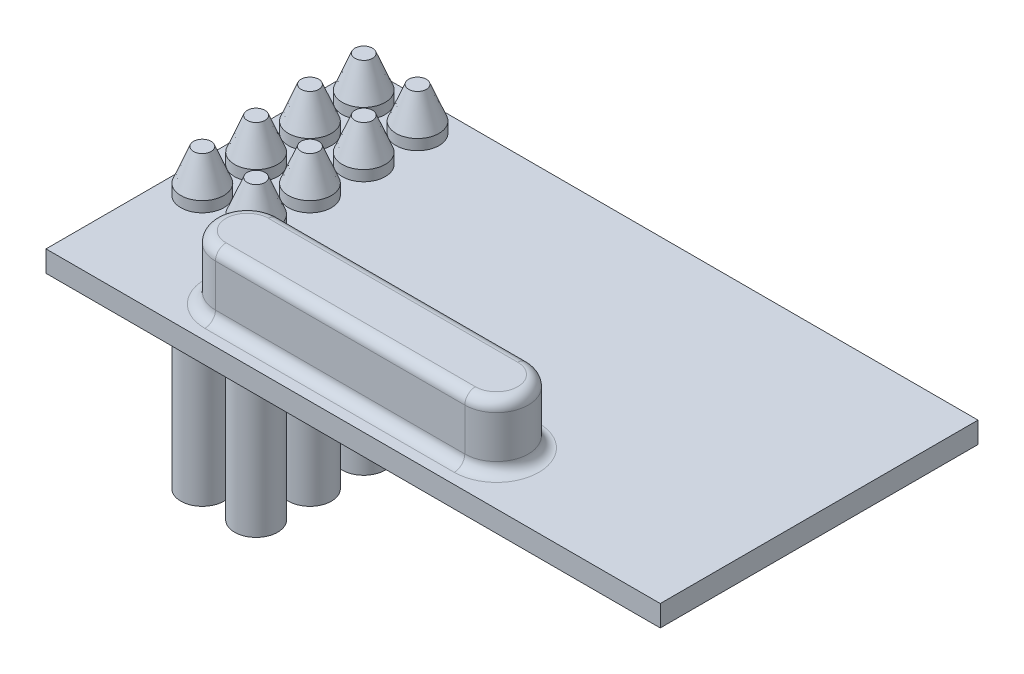
from build123d import *

# Parameters (mm, degrees)
ESQUISSE1_W             = 29
ESQUISSE1_H             = 15
BOSS_EXTRU_1_DEPTH      = 1
ESQUISSE2_R             = 1.016
BOSS_EXTRU_2_DEPTH      = 2
BOSS_EXTRU_2_DEPTH_BACK = 12
CHANFREIN1_SIZE         = 1.5
CHANFREIN1_SIZE2        = 0.6
CHANFREIN1_PART_2_SIZE  = 1.5
CHANFREIN1_PART_2_SIZE2 = 0.6
CHANFREIN1_PART_3_SIZE  = 1.5
CHANFREIN1_PART_3_SIZE2 = 0.6
CHANFREIN1_PART_4_SIZE  = 1.5
CHANFREIN1_PART_4_SIZE2 = 0.6
CHANFREIN1_PART_5_SIZE  = 1.5
CHANFREIN1_PART_5_SIZE2 = 0.6
CHANFREIN1_PART_6_SIZE  = 1.5
CHANFREIN1_PART_6_SIZE2 = 0.6
CHANFREIN1_PART_7_SIZE  = 1.5
CHANFREIN1_PART_7_SIZE2 = 0.6
CHANFREIN1_PART_8_SIZE  = 1.5
CHANFREIN1_PART_8_SIZE2 = 0.6
BOSS_EXTRU_3_DEPTH      = 3
CONG_2_R                = 0.5
CONG_3_R                = 0.5


with BuildPart() as part:
    # Esquisse1 → Boss.-Extru.1 (new body)
    with BuildSketch(Plane(origin=(0, 0, 0), x_dir=(1, 0, 0), z_dir=(0, 1, 0))):
        with Locations((14.5, 7.5)):
            Rectangle(ESQUISSE1_W, ESQUISSE1_H)
    extrude(amount=BOSS_EXTRU_1_DEPTH)

    # Esquisse2 → Boss.-Extru.2 (add, two sides)
    with BuildSketch(Plane(origin=(0, 1, 0), x_dir=(1, 0, 0), z_dir=(0, 1, 0))) as boss_extru_2_sk:
        with Locations((1.5, 13.5)):
            Circle(ESQUISSE2_R)
        with Locations((1.5, 10.96)):
            Circle(ESQUISSE2_R)
        with Locations((1.5, 8.42)):
            Circle(ESQUISSE2_R)
        with Locations((1.5, 5.88)):
            Circle(ESQUISSE2_R)
        with Locations((4.04, 10.96)):
            Circle(ESQUISSE2_R)
        with Locations((4.04, 8.42)):
            Circle(ESQUISSE2_R)
        with Locations((4.04, 5.88)):
            Circle(ESQUISSE2_R)
        with Locations((4.04, 13.5)):
            Circle(ESQUISSE2_R)
    extrude(amount=BOSS_EXTRU_2_DEPTH)
    extrude(boss_extru_2_sk.sketch, amount=-BOSS_EXTRU_2_DEPTH_BACK)

    # Chanfrein1
    chanfrein1_edges = [part.edges().sort_by_distance(p)[0] for p in [
        (0.484, 3, -13.5),
    ]]
    chanfrein1_side = [part.faces().sort_by_distance(p)[0] for p in [
        (0.484, 2, -13.5),
    ]]
    chamfer(chanfrein1_edges, length=CHANFREIN1_SIZE, length2=CHANFREIN1_SIZE2, reference=chanfrein1_side[0])

    # Chanfrein1 part 2
    chanfrein1_part_2_edges = [part.edges().sort_by_distance(p)[0] for p in [
        (0.484, 3, -10.96),
    ]]
    chanfrein1_part_2_side = [part.faces().sort_by_distance(p)[0] for p in [
        (0.484, 2, -10.96),
    ]]
    chamfer(chanfrein1_part_2_edges, length=CHANFREIN1_PART_2_SIZE, length2=CHANFREIN1_PART_2_SIZE2, reference=chanfrein1_part_2_side[0])

    # Chanfrein1 part 3
    chanfrein1_part_3_edges = [part.edges().sort_by_distance(p)[0] for p in [
        (0.484, 3, -8.42),
    ]]
    chanfrein1_part_3_side = [part.faces().sort_by_distance(p)[0] for p in [
        (0.484, 2, -8.42),
    ]]
    chamfer(chanfrein1_part_3_edges, length=CHANFREIN1_PART_3_SIZE, length2=CHANFREIN1_PART_3_SIZE2, reference=chanfrein1_part_3_side[0])

    # Chanfrein1 part 4
    chanfrein1_part_4_edges = [part.edges().sort_by_distance(p)[0] for p in [
        (0.484, 3, -5.88),
    ]]
    chanfrein1_part_4_side = [part.faces().sort_by_distance(p)[0] for p in [
        (0.484, 2, -5.88),
    ]]
    chamfer(chanfrein1_part_4_edges, length=CHANFREIN1_PART_4_SIZE, length2=CHANFREIN1_PART_4_SIZE2, reference=chanfrein1_part_4_side[0])

    # Chanfrein1 part 5
    chanfrein1_part_5_edges = [part.edges().sort_by_distance(p)[0] for p in [
        (3.024, 3, -10.96),
    ]]
    chanfrein1_part_5_side = [part.faces().sort_by_distance(p)[0] for p in [
        (3.024, 2, -10.96),
    ]]
    chamfer(chanfrein1_part_5_edges, length=CHANFREIN1_PART_5_SIZE, length2=CHANFREIN1_PART_5_SIZE2, reference=chanfrein1_part_5_side[0])

    # Chanfrein1 part 6
    chanfrein1_part_6_edges = [part.edges().sort_by_distance(p)[0] for p in [
        (3.024, 3, -8.42),
    ]]
    chanfrein1_part_6_side = [part.faces().sort_by_distance(p)[0] for p in [
        (3.024, 2, -8.42),
    ]]
    chamfer(chanfrein1_part_6_edges, length=CHANFREIN1_PART_6_SIZE, length2=CHANFREIN1_PART_6_SIZE2, reference=chanfrein1_part_6_side[0])

    # Chanfrein1 part 7
    chanfrein1_part_7_edges = [part.edges().sort_by_distance(p)[0] for p in [
        (3.024, 3, -5.88),
    ]]
    chanfrein1_part_7_side = [part.faces().sort_by_distance(p)[0] for p in [
        (3.024, 2, -5.88),
    ]]
    chamfer(chanfrein1_part_7_edges, length=CHANFREIN1_PART_7_SIZE, length2=CHANFREIN1_PART_7_SIZE2, reference=chanfrein1_part_7_side[0])

    # Chanfrein1 part 8
    chanfrein1_part_8_edges = [part.edges().sort_by_distance(p)[0] for p in [
        (3.024, 3, -13.5),
    ]]
    chanfrein1_part_8_side = [part.faces().sort_by_distance(p)[0] for p in [
        (3.024, 2, -13.5),
    ]]
    chamfer(chanfrein1_part_8_edges, length=CHANFREIN1_PART_8_SIZE, length2=CHANFREIN1_PART_8_SIZE2, reference=chanfrein1_part_8_side[0])

    # Esquisse3 → Boss.-Extru.3 (add)
    with BuildSketch(Plane(origin=(0, 1, 0), x_dir=(1, 0, 0), z_dir=(0, 1, 0))):
        with BuildLine():
            Line((7, 4), (18.771127801, 4))
            ThreePointArc((18.771127801, 4), (20.271127801, 2.5), (18.771127801, 1))
            Line((18.771127801, 1), (7, 1))
            ThreePointArc((7, 1), (5.5, 2.5), (7, 4))
        make_face()
    extrude(amount=BOSS_EXTRU_3_DEPTH)

    # Congé2
    cong_2_edges = [part.edges().sort_by_distance(p)[0] for p in [
        (5.5, 4, -2.5),
        (12.885563901, 4, -1),
        (20.271127801, 4, -2.5),
        (12.885563901, 4, -4),
    ]]
    fillet(cong_2_edges, radius=CONG_2_R)

    # Congé3
    cong_3_edges = [part.edges().sort_by_distance(p)[0] for p in [
        (5.5, 1, -2.5),
        (12.885563901, 1, -1),
        (20.271127801, 1, -2.5),
        (12.885563901, 1, -4),
    ]]
    fillet(cong_3_edges, radius=CONG_3_R)


solid = part.part
